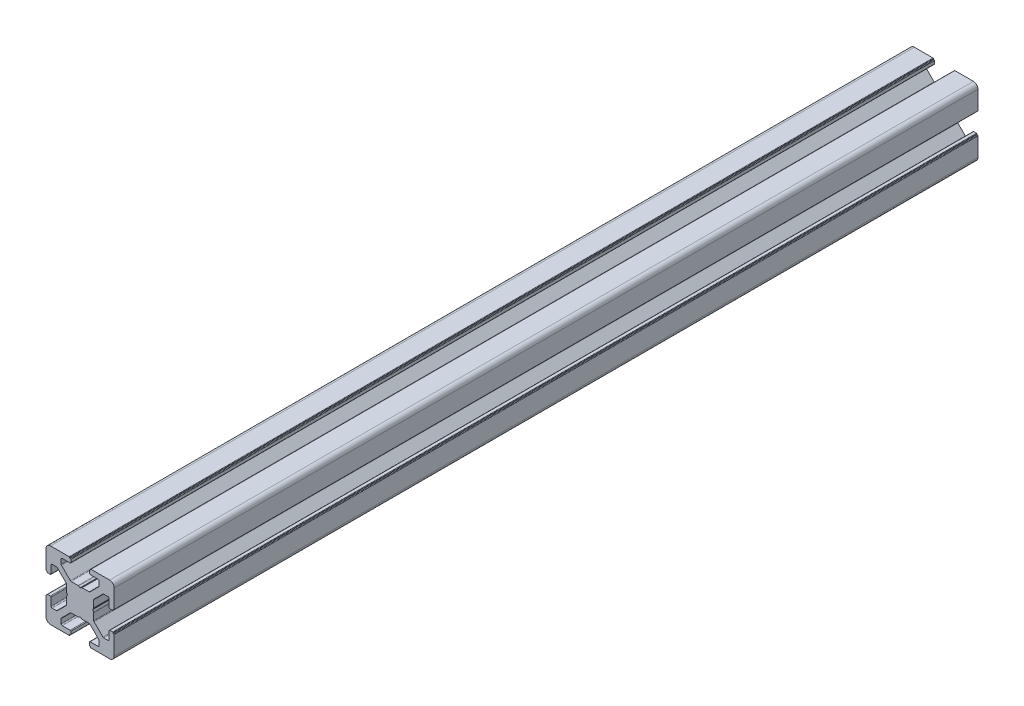
from build123d import *

# Parameters (mm, degrees)
BOSS_EXTRUDE1_DEPTH = 380


with BuildPart() as part:
    # Sketch1 → Boss-Extrude1 (new body)
    with BuildSketch(Plane.XY):
        with BuildLine():
            Line((-12.8, 4.4), (-12.8, 7.85))
            ThreePointArc((-12.8, 7.85), (-12.653553391, 8.203553391), (-12.3, 8.35))
            Line((-12.3, 8.35), (-10.395584412, 8.35))
            ThreePointArc((-10.395584412, 8.35), (-10.204242696, 8.311939766), (-10.042031022, 8.203553391))
            Line((-10.042031022, 8.203553391), (-6.146446609, 4.307968978))
            ThreePointArc((-6.146446609, 4.307968978), (-6.038060234, 4.145757304), (-6, 3.954415588))
            Line((-6, 3.954415588), (-6, 0.933974596))
            ThreePointArc((-6, 0.933974596), (-5.982962913, 0.804565074), (-5.933012702, 0.683974596))
            Line((-5.933012702, 0.683974596), (-5.538119785, 0))
            Line((-5.538119785, 0), (-5.933012702, -0.683974596))
            ThreePointArc((-5.933012702, -0.683974596), (-5.982962913, -0.804565074), (-6, -0.933974596))
            Line((-6, -0.933974596), (-6, -3.954415588))
            ThreePointArc((-6, -3.954415588), (-6.038060234, -4.145757304), (-6.146446609, -4.307968978))
            Line((-6.146446609, -4.307968978), (-10.042031022, -8.203553391))
            ThreePointArc((-10.042031022, -8.203553391), (-10.204242696, -8.311939766), (-10.395584412, -8.35))
            Line((-10.395584412, -8.35), (-12.3, -8.35))
            ThreePointArc((-12.3, -8.35), (-12.653553391, -8.203553391), (-12.8, -7.85))
            Line((-12.8, -7.85), (-12.8, -4.4))
            ThreePointArc((-12.8, -4.4), (-12.887867966, -4.187867966), (-13.1, -4.1))
            Line((-13.1, -4.1), (-14.3, -4.1))
            ThreePointArc((-14.3, -4.1), (-14.441421356, -4.158578644), (-14.5, -4.3))
            Line((-14.5, -4.3), (-14.5, -4.4))
            ThreePointArc((-14.5, -4.4), (-14.558578644, -4.541421356), (-14.7, -4.6))
            Line((-14.7, -4.6), (-14.8, -4.6))
            ThreePointArc((-14.8, -4.6), (-14.941421356, -4.658578644), (-15, -4.8))
            Line((-15, -4.8), (-15, -13))
            ThreePointArc((-15, -13), (-14.414213562, -14.414213562), (-13, -15))
            Line((-13, -15), (-4.8, -15))
            ThreePointArc((-4.8, -15), (-4.658578644, -14.941421356), (-4.6, -14.8))
            Line((-4.6, -14.8), (-4.6, -14.7))
            ThreePointArc((-4.6, -14.7), (-4.541421356, -14.558578644), (-4.4, -14.5))
            Line((-4.4, -14.5), (-4.3, -14.5))
            ThreePointArc((-4.3, -14.5), (-4.158578644, -14.441421356), (-4.1, -14.3))
            Line((-4.1, -14.3), (-4.1, -13.1))
            ThreePointArc((-4.1, -13.1), (-4.187867966, -12.887867966), (-4.4, -12.8))
            Line((-4.4, -12.8), (-7.85, -12.8))
            ThreePointArc((-7.85, -12.8), (-8.203553391, -12.653553391), (-8.35, -12.3))
            Line((-8.35, -12.3), (-8.35, -10.395584412))
            ThreePointArc((-8.35, -10.395584412), (-8.311939766, -10.204242696), (-8.203553391, -10.042031022))
            Line((-8.203553391, -10.042031022), (-4.307968978, -6.146446609))
            ThreePointArc((-4.307968978, -6.146446609), (-4.145757304, -6.038060234), (-3.954415588, -6))
            Line((-3.954415588, -6), (-0.933974596, -6))
            ThreePointArc((-0.933974596, -6), (-0.804565074, -5.982962913), (-0.683974596, -5.933012702))
            Line((-0.683974596, -5.933012702), (0, -5.538119785))
            Line((0, -5.538119785), (0.683974596, -5.933012702))
            ThreePointArc((0.683974596, -5.933012702), (0.804565074, -5.982962913), (0.933974596, -6))
            Line((0.933974596, -6), (3.954415588, -6))
            ThreePointArc((3.954415588, -6), (4.145757304, -6.038060234), (4.307968978, -6.146446609))
            Line((4.307968978, -6.146446609), (8.203553391, -10.042031022))
            ThreePointArc((8.203553391, -10.042031022), (8.311939766, -10.204242696), (8.35, -10.395584412))
            Line((8.35, -10.395584412), (8.35, -12.3))
            ThreePointArc((8.35, -12.3), (8.203553391, -12.653553391), (7.85, -12.8))
            Line((7.85, -12.8), (4.4, -12.8))
            ThreePointArc((4.4, -12.8), (4.187867966, -12.887867966), (4.1, -13.1))
            Line((4.1, -13.1), (4.1, -14.3))
            ThreePointArc((4.1, -14.3), (4.158578644, -14.441421356), (4.3, -14.5))
            Line((4.3, -14.5), (4.4, -14.5))
            ThreePointArc((4.4, -14.5), (4.541421356, -14.558578644), (4.6, -14.7))
            Line((4.6, -14.7), (4.6, -14.8))
            ThreePointArc((4.6, -14.8), (4.658578644, -14.941421356), (4.8, -15))
            Line((4.8, -15), (13, -15))
            ThreePointArc((13, -15), (14.414213562, -14.414213562), (15, -13))
            Line((15, -13), (15, -4.8))
            ThreePointArc((15, -4.8), (14.941421356, -4.658578644), (14.8, -4.6))
            Line((14.8, -4.6), (14.7, -4.6))
            ThreePointArc((14.7, -4.6), (14.558578644, -4.541421356), (14.5, -4.4))
            Line((14.5, -4.4), (14.5, -4.3))
            ThreePointArc((14.5, -4.3), (14.441421356, -4.158578644), (14.3, -4.1))
            Line((14.3, -4.1), (13.1, -4.1))
            ThreePointArc((13.1, -4.1), (12.887867966, -4.187867966), (12.8, -4.4))
            Line((12.8, -4.4), (12.8, -7.85))
            ThreePointArc((12.8, -7.85), (12.653553391, -8.203553391), (12.3, -8.35))
            Line((12.3, -8.35), (10.395584412, -8.35))
            ThreePointArc((10.395584412, -8.35), (10.204242696, -8.311939766), (10.042031022, -8.203553391))
            Line((10.042031022, -8.203553391), (6.146446609, -4.307968978))
            ThreePointArc((6.146446609, -4.307968978), (6.038060234, -4.145757304), (6, -3.954415588))
            Line((6, -3.954415588), (6, -0.933974596))
            ThreePointArc((6, -0.933974596), (5.982962913, -0.804565074), (5.933012702, -0.683974596))
            Line((5.933012702, -0.683974596), (5.538119785, 0))
            Line((5.538119785, 0), (5.933012702, 0.683974596))
            ThreePointArc((5.933012702, 0.683974596), (5.982962913, 0.804565074), (6, 0.933974596))
            Line((6, 0.933974596), (6, 3.954415588))
            ThreePointArc((6, 3.954415588), (6.038060234, 4.145757304), (6.146446609, 4.307968978))
            Line((6.146446609, 4.307968978), (10.042031022, 8.203553391))
            ThreePointArc((10.042031022, 8.203553391), (10.204242696, 8.311939766), (10.395584412, 8.35))
            Line((10.395584412, 8.35), (12.3, 8.35))
            ThreePointArc((12.3, 8.35), (12.653553391, 8.203553391), (12.8, 7.85))
            Line((12.8, 7.85), (12.8, 4.4))
            ThreePointArc((12.8, 4.4), (12.887867966, 4.187867966), (13.1, 4.1))
            Line((13.1, 4.1), (14.3, 4.1))
            ThreePointArc((14.3, 4.1), (14.441421356, 4.158578644), (14.5, 4.3))
            Line((14.5, 4.3), (14.5, 4.4))
            ThreePointArc((14.5, 4.4), (14.558578644, 4.541421356), (14.7, 4.6))
            Line((14.7, 4.6), (14.8, 4.6))
            ThreePointArc((14.8, 4.6), (14.941421356, 4.658578644), (15, 4.8))
            Line((15, 4.8), (15, 13))
            ThreePointArc((15, 13), (14.414213562, 14.414213562), (13, 15))
            Line((13, 15), (4.8, 15))
            ThreePointArc((4.8, 15), (4.658578644, 14.941421356), (4.6, 14.8))
            Line((4.6, 14.8), (4.6, 14.7))
            ThreePointArc((4.6, 14.7), (4.541421356, 14.558578644), (4.4, 14.5))
            Line((4.4, 14.5), (4.3, 14.5))
            ThreePointArc((4.3, 14.5), (4.158578644, 14.441421356), (4.1, 14.3))
            Line((4.1, 14.3), (4.1, 13.1))
            ThreePointArc((4.1, 13.1), (4.187867966, 12.887867966), (4.4, 12.8))
            Line((4.4, 12.8), (7.85, 12.8))
            ThreePointArc((7.85, 12.8), (8.203553391, 12.653553391), (8.35, 12.3))
            Line((8.35, 12.3), (8.35, 10.395584412))
            ThreePointArc((8.35, 10.395584412), (8.311939766, 10.204242696), (8.203553391, 10.042031022))
            Line((8.203553391, 10.042031022), (4.307968978, 6.146446609))
            ThreePointArc((4.307968978, 6.146446609), (4.145757304, 6.038060234), (3.954415588, 6))
            Line((3.954415588, 6), (0.933974596, 6))
            ThreePointArc((0.933974596, 6), (0.804565074, 5.982962913), (0.683974596, 5.933012702))
            Line((0.683974596, 5.933012702), (0, 5.538119785))
            Line((0, 5.538119785), (-0.683974596, 5.933012702))
            ThreePointArc((-0.683974596, 5.933012702), (-0.804565074, 5.982962913), (-0.933974596, 6))
            Line((-0.933974596, 6), (-3.954415588, 6))
            ThreePointArc((-3.954415588, 6), (-4.145757304, 6.038060234), (-4.307968978, 6.146446609))
            Line((-4.307968978, 6.146446609), (-8.203553391, 10.042031022))
            ThreePointArc((-8.203553391, 10.042031022), (-8.311939766, 10.204242696), (-8.35, 10.395584412))
            Line((-8.35, 10.395584412), (-8.35, 12.3))
            ThreePointArc((-8.35, 12.3), (-8.203553391, 12.653553391), (-7.85, 12.8))
            Line((-7.85, 12.8), (-4.4, 12.8))
            ThreePointArc((-4.4, 12.8), (-4.187867966, 12.887867966), (-4.1, 13.1))
            Line((-4.1, 13.1), (-4.1, 14.3))
            ThreePointArc((-4.1, 14.3), (-4.158578644, 14.441421356), (-4.3, 14.5))
            Line((-4.3, 14.5), (-4.4, 14.5))
            ThreePointArc((-4.4, 14.5), (-4.541421356, 14.558578644), (-4.6, 14.7))
            Line((-4.6, 14.7), (-4.6, 14.8))
            ThreePointArc((-4.6, 14.8), (-4.658578644, 14.941421356), (-4.8, 15))
            Line((-4.8, 15), (-13, 15))
            ThreePointArc((-13, 15), (-14.414213562, 14.414213562), (-15, 13))
            Line((-15, 13), (-15, 4.8))
            ThreePointArc((-15, 4.8), (-14.941421356, 4.658578644), (-14.8, 4.6))
            Line((-14.8, 4.6), (-14.7, 4.6))
            ThreePointArc((-14.7, 4.6), (-14.558578644, 4.541421356), (-14.5, 4.4))
            Line((-14.5, 4.4), (-14.5, 4.3))
            ThreePointArc((-14.5, 4.3), (-14.441421356, 4.158578644), (-14.3, 4.1))
            Line((-14.3, 4.1), (-13.1, 4.1))
            ThreePointArc((-13.1, 4.1), (-12.887867966, 4.187867966), (-12.8, 4.4))
        make_face()
    extrude(amount=BOSS_EXTRUDE1_DEPTH)


solid = part.part
